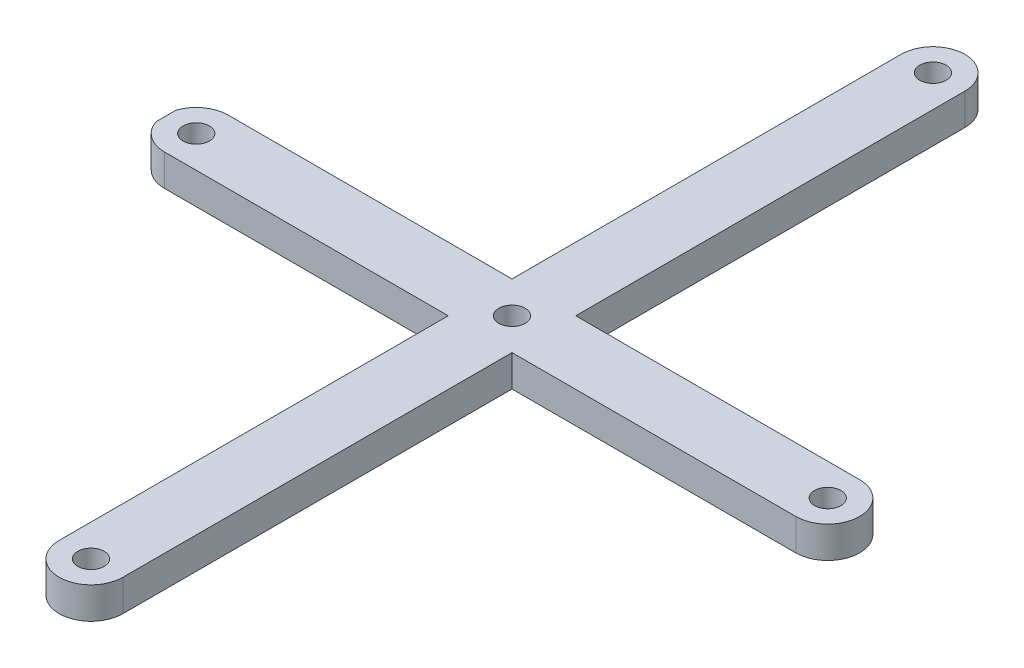
from build123d import *

# Parameters (mm, degrees)
SKETCH1_R           = 0.25
BOSS_EXTRUDE1_DEPTH = 0.6
SKETCH2_R           = 0.25
CUT_EXTRUDE1_DEPTH  = 1.6


with BuildPart() as part:
    # Sketch1 → Boss-Extrude1 (new body)
    with BuildSketch(Plane(origin=(0, 0, 0), x_dir=(1, 0, 0), z_dir=(0, 1, 0))):
        with BuildLine():
            Line((2.454545455, 3.424242424), (2.454545455, 10.818181818))
            ThreePointArc((2.454545455, 10.818181818), (1.848484848, 11.424242424), (1.242424242, 10.818181818))
            Line((1.242424242, 10.818181818), (1.242424242, 3.424242424))
            Line((1.242424242, 3.424242424), (-4.151515152, 3.424242424))
            ThreePointArc((-4.151515152, 3.424242424), (-4.506914305, 3.309100243), (-4.727272727, 3.007424182))
            Line((-4.727272727, 3.007424182), (-4.727272727, 2.628939455))
            ThreePointArc((-4.727272727, 2.628939455), (-4.506914305, 2.327263393), (-4.151515152, 2.212121212))
            Line((-4.151515152, 2.212121212), (1.242424242, 2.212121212))
            Line((1.242424242, 2.212121212), (1.242424242, -5.181818182))
            ThreePointArc((1.242424242, -5.181818182), (1.848484848, -5.787878788), (2.454545455, -5.181818182))
            Line((2.454545455, -5.181818182), (2.454545455, 2.212121212))
            Line((2.454545455, 2.212121212), (7.848484848, 2.212121212))
            ThreePointArc((7.848484848, 2.212121212), (8.454545455, 2.818181818), (7.848484848, 3.424242424))
            Line((7.848484848, 3.424242424), (2.454545455, 3.424242424))
        make_face()
        with Locations((1.848484848, 10.818181818)):
            Circle(SKETCH1_R, mode=Mode.SUBTRACT)
        with Locations((1.848484848, -5.181818182)):
            Circle(SKETCH1_R, mode=Mode.SUBTRACT)
        with Locations((-4.151515152, 2.818181818)):
            Circle(SKETCH1_R, mode=Mode.SUBTRACT)
        with Locations((7.848484848, 2.818181818)):
            Circle(SKETCH1_R, mode=Mode.SUBTRACT)
    extrude(amount=BOSS_EXTRUDE1_DEPTH)

    # Sketch2 → Cut-Extrude1 (cut, through all)
    with BuildSketch(Plane(origin=(0, 0.6, 0), x_dir=(1, 0, 0), z_dir=(0, 1, 0))):
        with Locations((1.848484848, 2.818181818)):
            Circle(SKETCH2_R)
    extrude(amount=-CUT_EXTRUDE1_DEPTH, mode=Mode.SUBTRACT)


solid = part.part
